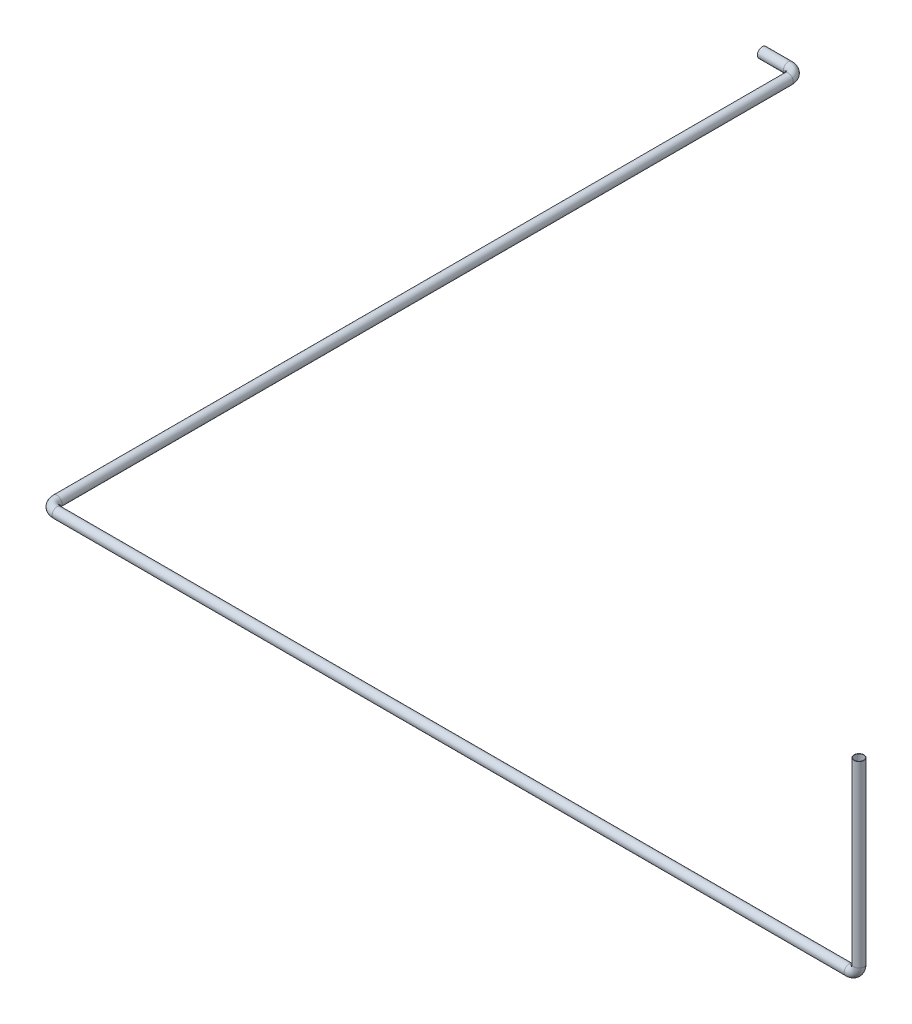
from build123d import *

# Parameters (mm, degrees)
SWEEP_THIN1_PROFILE_R   = 15
SWEEP_THIN1_PROFILE_R_2 = 14


with BuildPart() as part:
    # Sweep-Thin1: sweep along a curve in space
    with BuildLine() as sweep_thin1_path:
        Line((-31937.449283249, -16257.859506292, 41333.824329306), (-31937.449283249, -16801.020828117, 41333.824329306))
        ThreePointArc((-31937.449283249, -16801.020828117, 41333.824329306), (-31946.236079813, -16822.234031553, 41333.824329306), (-31967.449283249, -16831.020828117, 41333.824329306))
        Line((-31967.449283249, -16831.020828117, 41333.824329306), (-34374.473315276, -16831.020828117, 41333.824329306))
        ThreePointArc((-34374.473315276, -16831.020828117, 41333.824329306), (-34395.686518712, -16831.020828117, 41325.037532741), (-34404.473315276, -16831.020828117, 41303.824329306))
        Line((-34404.473315276, -16831.020828117, 41303.824329306), (-34404.473315276, -16831.020828117, 39081.700196057))
        ThreePointArc((-34404.473315276, -16831.020828117, 39081.700196057), (-34413.260111841, -16831.020828117, 39060.486992621), (-34434.473315276, -16831.020828117, 39051.700196057))
        Line((-34434.473315276, -16831.020828117, 39051.700196057), (-34513.51869548, -16831.020828117, 39051.700196057))
    # Sweep-Thin1 profile (on start of the path) → Sweep-Thin1 (sweep)
    with BuildSketch(Plane(origin=(-31937.449283249, -16257.859506292, 41333.824329306), x_dir=(0, 0, -1), z_dir=(0, -1, 0))):
        Circle(SWEEP_THIN1_PROFILE_R)
        Circle(SWEEP_THIN1_PROFILE_R_2, mode=Mode.SUBTRACT)
    sweep(path=sweep_thin1_path.line)


solid = part.part
